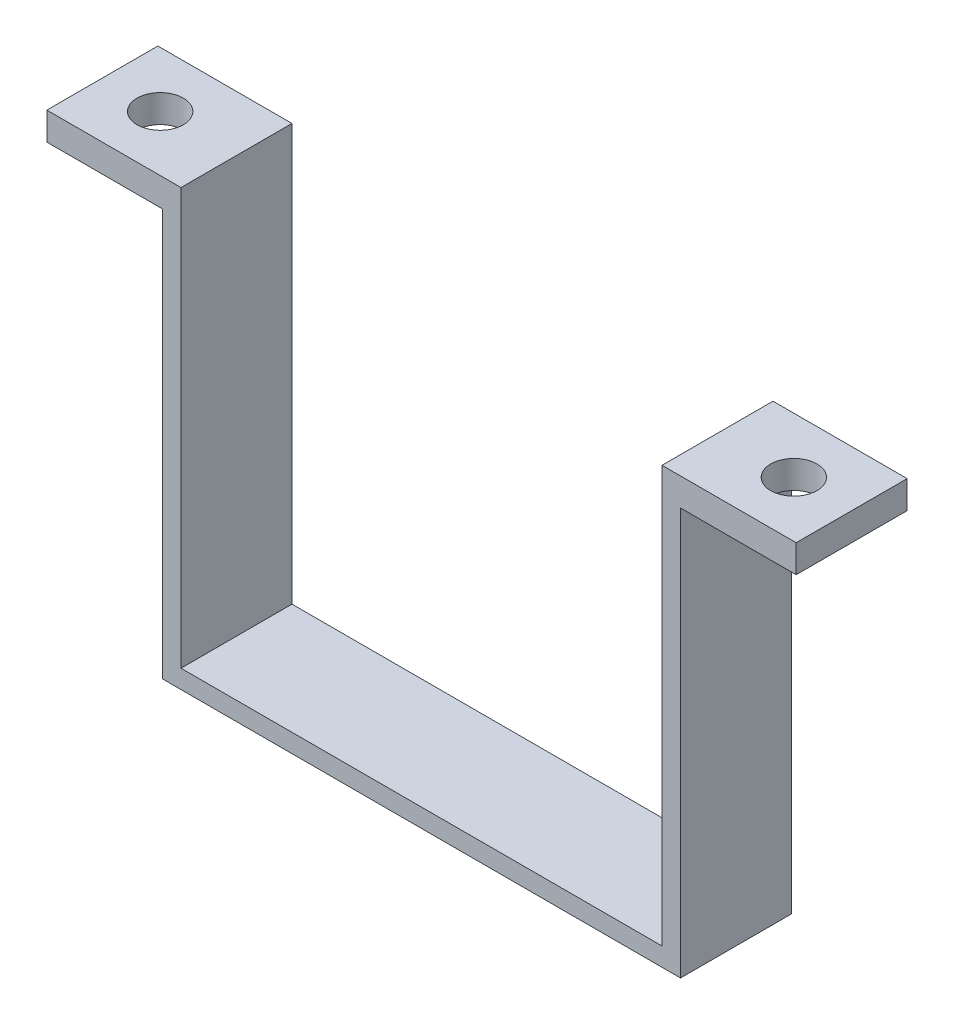
from build123d import *

# Parameters (mm, degrees)
BOSS_EXTRUDE1_DEPTH = 12
SKETCH3_W           = 12
SKETCH3_H           = 3
BOSS_EXTRUDE2_DEPTH = 2.5
SKETCH4_W           = 12
SKETCH4_H           = 3
BOSS_EXTRUDE3_DEPTH = 2.5
SKETCH6_R           = 2.5
CUT_EXTRUDE1_DEPTH  = 10
SKETCH7_R           = 2.5
CUT_EXTRUDE2_DEPTH  = 10


with BuildPart() as part:
    # Sketch1 → Boss-Extrude1 (new body)
    with BuildSketch(Plane.XY):
        Polygon((0, 0), (0, 3), (12, 3), (12, 0), (2, 0), (2, -44), (-54, -44), (-54, 0), (-64, 0), (-64, 3), (-52, 3), (-52, -42), (0, -42), align=None)
    extrude(amount=BOSS_EXTRUDE1_DEPTH)

    # Sketch3 → Boss-Extrude2 (add)
    with BuildSketch(Plane(origin=(12, 0, 0), x_dir=(0, 0, -1), z_dir=(1, 0, 0))):
        with Locations((-6, 1.5)):
            Rectangle(SKETCH3_W, SKETCH3_H)
    extrude(amount=BOSS_EXTRUDE2_DEPTH)

    # Sketch4 → Boss-Extrude3 (add)
    with BuildSketch(Plane.ZY.offset(64)):
        with Locations((6, 1.5)):
            Rectangle(SKETCH4_W, SKETCH4_H)
    extrude(amount=BOSS_EXTRUDE3_DEPTH)

    # Sketch6 → Cut-Extrude1 (cut)
    with BuildSketch(Plane.XZ):
        with Locations((-60.25, 6)):
            Circle(SKETCH6_R)
    extrude(amount=-CUT_EXTRUDE1_DEPTH, mode=Mode.SUBTRACT)

    # Sketch7 → Cut-Extrude2 (cut)
    with BuildSketch(Plane.XZ):
        with Locations((8.25, 6)):
            Circle(SKETCH7_R)
    extrude(amount=-CUT_EXTRUDE2_DEPTH, mode=Mode.SUBTRACT)


solid = part.part
